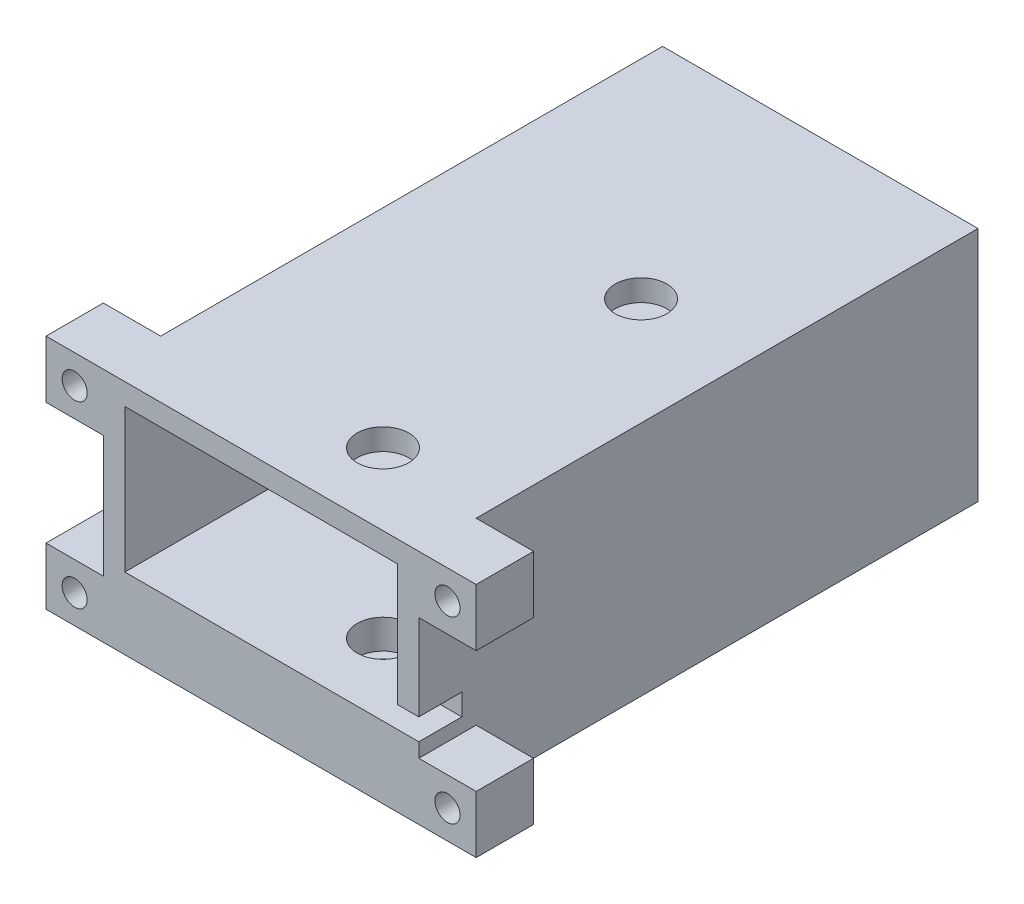
from build123d import *

# Parameters (mm, degrees)
SKETCH_1_W                 = 44
SKETCH_1_H                 = 78
EXTRUDE_1_DEPTH            = 33
SHELL_1_T                  = -3
SHELL_1_THICKNESS_2_FACE_W = 75
SHELL_1_THICKNESS_2_FACE_H = 38
SHELL_1_THICKNESS_2_DEPTH  = 7
SKETCH_3_R                 = 3.6
CUT_EXTRUDE_1_DEPTH        = 4.1
CUT_EXTRUDE_2_REACH        = 52.339
SKETCH_4_R                 = 2.25
SKETCH_5_W                 = 3
SKETCH_5_H                 = 3
CUT_EXTRUDE_3_DEPTH        = 6
SKETCH_6_W                 = 8
SKETCH_6_H                 = 8
SKETCH_6_R                 = 1.75
EXTRUDE_2_DEPTH            = 8
CUT_EXTRUDE_4_DEPTH        = 2.6
CUT_EXTRUDE_5_REACH        = 89.258
SKETCH_8_R                 = 5
CUT_EXTRUDE_6_REACH        = 61.245
SKETCH_9_R                 = 3.6


with BuildPart() as part:
    # 草圖1 → 填料-伸長1 (new body)
    with BuildSketch(Plane(origin=(0, 0, 0), x_dir=(1, 0, 0), z_dir=(0, 1, 0))):
        Rectangle(SKETCH_1_W, SKETCH_1_H)
    extrude(amount=EXTRUDE_1_DEPTH)

    # 薄殼1
    shell_1_openings = [part.faces().sort_by_distance(p)[0] for p in [
        (0, 16.5, 39),
    ]]
    offset(amount=SHELL_1_T, openings=shell_1_openings, kind=Kind.INTERSECTION)

    # 薄殼1 thickness 2 face (on inner face of the shell) → 薄殼1 thickness 2 (add)
    with BuildSketch(Plane(origin=(0, 3, 1.5), x_dir=(0, 0, -1), z_dir=(0, -1, 0))):
        Rectangle(SHELL_1_THICKNESS_2_FACE_W, SHELL_1_THICKNESS_2_FACE_H)
    extrude(amount=-SHELL_1_THICKNESS_2_DEPTH)

    # 草圖3 → 除料-伸長1 (cut)
    with BuildSketch(Plane(origin=(0, 10, 0), x_dir=(1, 0, 0), z_dir=(0, 1, 0))):
        with Locations(Location((7, 7, 0), (0, 0, 270))):
            Circle(SKETCH_3_R)
        with Locations(Location((7, -29, 0), (0, 0, 270))):
            Circle(SKETCH_3_R)
    extrude(amount=-CUT_EXTRUDE_1_DEPTH, mode=Mode.SUBTRACT)

    # 草圖4 → 除料-伸長2 (cut, up to next)
    with BuildSketch(Plane(origin=(0, 10, 0), x_dir=(1, 0, 0), z_dir=(0, 1, 0)), mode=Mode.PRIVATE) as cut_extrude_2_sk1:
        with Locations(Location((7, 7, 0), (0, 0, 270))):
            Circle(SKETCH_4_R)
    cut_extrude_2_tool1 = extrude(cut_extrude_2_sk1.sketch, amount=-CUT_EXTRUDE_2_REACH, mode=Mode.PRIVATE) & part.part
    # 草圖4 → 除料-伸長2 (cut, up to next)
    with BuildSketch(Plane(origin=(0, 10, 0), x_dir=(1, 0, 0), z_dir=(0, 1, 0)), mode=Mode.PRIVATE) as cut_extrude_2_sk2:
        with Locations(Location((7, -29, 0), (0, 0, 270))):
            Circle(SKETCH_4_R)
    cut_extrude_2_tool2 = extrude(cut_extrude_2_sk2.sketch, amount=-CUT_EXTRUDE_2_REACH, mode=Mode.PRIVATE) & part.part
    add(cut_extrude_2_tool1.solids().sort_by_distance((7, 10, -7))[0], mode=Mode.SUBTRACT)
    add(cut_extrude_2_tool2.solids().sort_by_distance((7, 10, 29))[0], mode=Mode.SUBTRACT)

    # 草圖5 → 除料-伸長3 (cut)
    with BuildSketch(Plane.XY.offset(39)):
        with Locations((20.5, 11.5)):
            Rectangle(SKETCH_5_W, SKETCH_5_H)
    extrude(amount=-CUT_EXTRUDE_3_DEPTH, mode=Mode.SUBTRACT)

    # 草圖6 → 填料-伸長2 (add)
    with BuildSketch(Plane.XY.offset(39)):
        with Locations((-26, 29)):
            Rectangle(SKETCH_6_W, SKETCH_6_H)
        with Locations((-26, 29)):
            Circle(SKETCH_6_R, mode=Mode.SUBTRACT)
        with Locations((-26, 4)):
            Rectangle(SKETCH_6_W, SKETCH_6_H)
        with Locations((-26, 4)):
            Circle(SKETCH_6_R, mode=Mode.SUBTRACT)
        with Locations((26, 4)):
            Rectangle(SKETCH_6_W, SKETCH_6_H)
        with Locations(Location((26, 4, 0), (0, 0, 180))):
            Circle(SKETCH_6_R, mode=Mode.SUBTRACT)
        with Locations((26, 29)):
            Rectangle(SKETCH_6_W, SKETCH_6_H)
        with Locations(Location((26, 29, 0), (0, 0, 180))):
            Circle(SKETCH_6_R, mode=Mode.SUBTRACT)
    extrude(amount=-EXTRUDE_2_DEPTH)

    # 草圖7 → 除料-伸長4 (cut)
    with BuildSketch(Plane(origin=(0, 0, 31), x_dir=(-1, 0, 0), z_dir=(0, 0, -1))):
        Polygon((27.616580754, 6.8), (29.233161507, 4), (27.616580754, 1.2), (24.383419246, 1.2), (22.766838493, 4), (24.383419246, 6.8), align=None)
        Polygon((-22.766838493, 29), (-24.383419246, 31.8), (-27.616580754, 31.8), (-29.233161507, 29), (-27.616580754, 26.2), (-24.383419246, 26.2), align=None)
        Polygon((-29.233161507, 4), (-27.616580754, 1.2), (-24.383419246, 1.2), (-22.766838493, 4), (-24.383419246, 6.8), (-27.616580754, 6.8), align=None)
        Polygon((24.383419246, 26.2), (22.766838493, 29), (24.383419246, 31.8), (27.616580754, 31.8), (29.233161507, 29), (27.616580754, 26.2), align=None)
    extrude(amount=-CUT_EXTRUDE_4_DEPTH, mode=Mode.SUBTRACT)

    # 草圖8 → 除料-伸長5 (cut, up to next)
    with BuildSketch(Plane.XY.offset(-36), mode=Mode.PRIVATE) as cut_extrude_5_sk1:
        with Locations((0, 20)):
            Circle(SKETCH_8_R)
    cut_extrude_5_tool1 = extrude(cut_extrude_5_sk1.sketch, amount=-CUT_EXTRUDE_5_REACH, mode=Mode.PRIVATE) & part.part
    add(cut_extrude_5_tool1.solids().sort_by_distance((0, 20, -36))[0], mode=Mode.SUBTRACT)

    # 草圖9 → 除料-伸長6 (cut, up to next)
    with BuildSketch(Plane(origin=(0, 33, 0), x_dir=(1, 0, 0), z_dir=(0, 1, 0)), mode=Mode.PRIVATE) as cut_extrude_6_sk1:
        with Locations(Location((7, 7, 0), (0, 0, 270))):
            Circle(SKETCH_9_R)
    cut_extrude_6_tool1 = extrude(cut_extrude_6_sk1.sketch, amount=-CUT_EXTRUDE_6_REACH, mode=Mode.PRIVATE) & part.part
    # 草圖9 → 除料-伸長6 (cut, up to next)
    with BuildSketch(Plane(origin=(0, 33, 0), x_dir=(1, 0, 0), z_dir=(0, 1, 0)), mode=Mode.PRIVATE) as cut_extrude_6_sk2:
        with Locations(Location((7, -29, 0), (0, 0, 270))):
            Circle(SKETCH_9_R)
    cut_extrude_6_tool2 = extrude(cut_extrude_6_sk2.sketch, amount=-CUT_EXTRUDE_6_REACH, mode=Mode.PRIVATE) & part.part
    add(cut_extrude_6_tool1.solids().sort_by_distance((7, 33, -7))[0], mode=Mode.SUBTRACT)
    add(cut_extrude_6_tool2.solids().sort_by_distance((7, 33, 29))[0], mode=Mode.SUBTRACT)


solid = part.part
